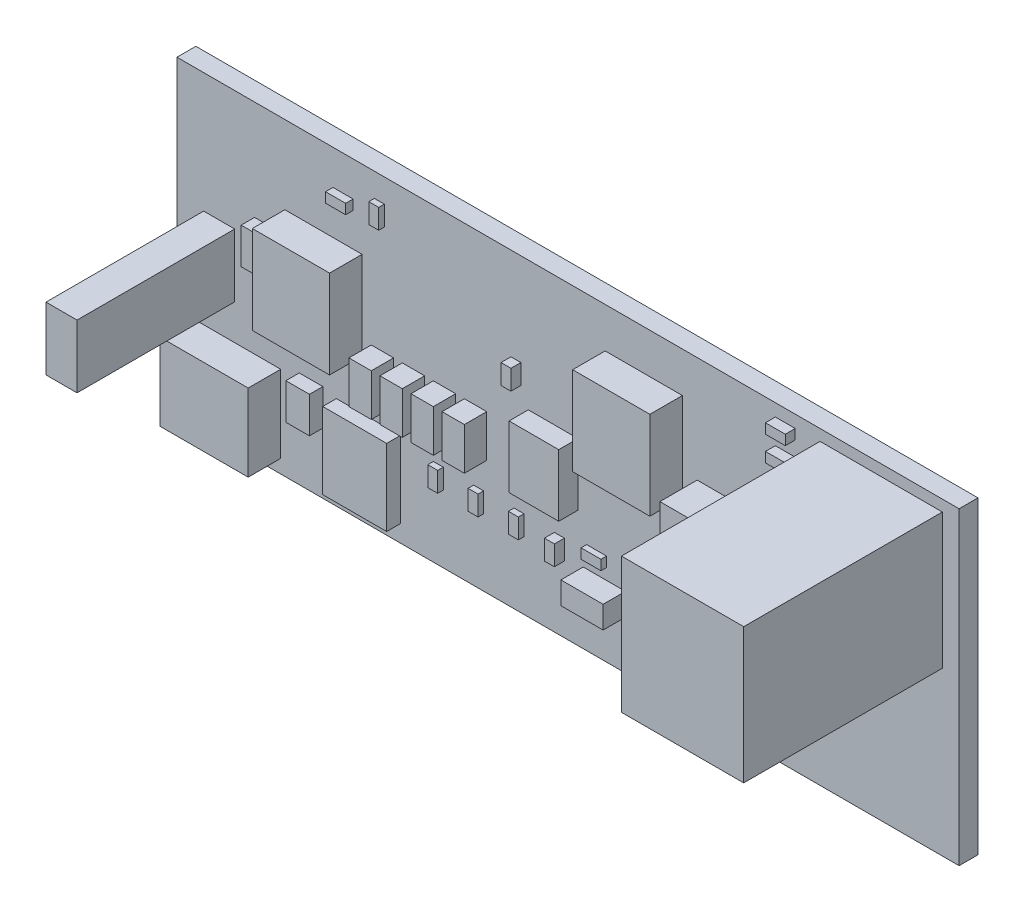
from build123d import *

# Parameters (mm, degrees)
SKETCH_1_W                  = 63
SKETCH_1_H                  = 24.9
BOARD_DEPTH                 = 1.522
SKETCH_2_W                  = 2.5
SKETCH_2_H                  = 5.08
TE_826629_2_1_DEPTH         = 12.7
EXTRUDE_C1206_1_DEPTH       = 1.8
SKETCH_4_W                  = 1.9
SKETCH_4_H                  = 2.9
DO_219AB_1_DEPTH            = 1.08
EXTRUDE_C1206_2_DEPTH       = 1.8
SKETCH_6_W                  = 0.8
SKETCH_6_H                  = 1.6001
EXTRUDE_C0603_1_DEPTH       = 0.8
SKETCH_7_W                  = 9.85
SKETCH_7_H                  = 10.9
EXTRUDE_4_1775099_0_1_DEPTH = 16
SKETCH_8_W                  = 5.15
SKETCH_8_H                  = 6.15
SON_8_1_DEPTH               = 1.1
SKETCH_9_W                  = 6.22
SKETCH_9_H                  = 7.11
DO_214AB_1_DEPTH            = 2.62
SKETCH_10_W                 = 7.11
SKETCH_10_H                 = 6.22
DO_214AB_2_DEPTH            = 2.62
SKETCH_11_W                 = 1.9
SKETCH_11_H                 = 2.9
DO_219AB_2_DEPTH            = 1.08
SKETCH_12_W                 = 6.22
SKETCH_12_H                 = 7.11
DO_214AB_3_DEPTH            = 2.62
SKETCH_13_W                 = 1.6
SKETCH_13_H                 = 0.8
EXTRUDE_R0603_1_DEPTH       = 0.45
SKETCH_14_W                 = 1.6
SKETCH_14_H                 = 0.8
EXTRUDE_R0603_2_DEPTH       = 0.45
SKETCH_15_W                 = 1.6
SKETCH_15_H                 = 0.8
EXTRUDE_R0603_3_DEPTH       = 0.45
SKETCH_16_W                 = 1.6
SKETCH_16_H                 = 0.8
EXTRUDE_R0603_4_DEPTH       = 0.45
SKETCH_17_W                 = 0.8
SKETCH_17_H                 = 1.6
EXTRUDE_R0603_5_DEPTH       = 0.45
SKETCH_18_W                 = 0.8
SKETCH_18_H                 = 1.6
EXTRUDE_R0603_6_DEPTH       = 0.45
SKETCH_19_W                 = 0.8
SKETCH_19_H                 = 1.6
EXTRUDE_R0603_7_DEPTH       = 0.45
SKETCH_20_W                 = 0.8
SKETCH_20_H                 = 1.6
EXTRUDE_R0603_8_DEPTH       = 0.45
SKETCH_21_W                 = 0.8
SKETCH_21_H                 = 1.6
EXTRUDE_R0603_9_DEPTH       = 0.45
SKETCH_22_W                 = 7.6
SKETCH_22_H                 = 6.9
SRP_2_670X660X280_1_DEPTH   = 3
SKETCH_23_W                 = 1.6201
SKETCH_23_H                 = 0.8
HL0603_1_DEPTH              = 0.6
SKETCH_24_W                 = 1.6201
SKETCH_24_H                 = 0.8
HL0603_2_DEPTH              = 0.6
SKETCH_25_W                 = 4
SKETCH_25_H                 = 5
HSOIC_8_1_DEPTH             = 1.55
SKETCH_26_W                 = 1.6001
SKETCH_26_H                 = 0.8
EXTRUDE_C0603_2_DEPTH       = 0.8
SKETCH_27_W                 = 1.6001
SKETCH_27_H                 = 0.8
EXTRUDE_C0603_3_DEPTH       = 0.8
SKETCH_28_W                 = 1.6001
SKETCH_28_H                 = 0.8
EXTRUDE_C0603_4_DEPTH       = 0.8
SKETCH_29_W                 = 1.6001
SKETCH_29_H                 = 0.8
EXTRUDE_C0603_5_DEPTH       = 0.8
SKETCH_30_W                 = 0.8
SKETCH_30_H                 = 1.6001
EXTRUDE_C0603_6_DEPTH       = 0.8
EXTRUDE_C1206_3_DEPTH       = 1.8
EXTRUDE_C1206_4_DEPTH       = 1.8
EXTRUDE_C1206_5_DEPTH       = 1.8


with BuildPart() as part:
    # Эскиз1 → BOARD (new body)
    with BuildSketch(Plane.XY):
        with Locations((31.5, 12.45)):
            Rectangle(SKETCH_1_W, SKETCH_1_H)
    extrude(amount=BOARD_DEPTH)


with BuildPart() as body_2:
    # Эскиз2 → TE_826629-2-1 (new body)
    with BuildSketch(Plane.XY.offset(1.522)):
        with Locations((3.4002, 12.6998)):
            Rectangle(SKETCH_2_W, SKETCH_2_H)
    extrude(amount=TE_826629_2_1_DEPTH)


with BuildPart() as body_3:
    # Эскиз3 → C1206-1 (new body)
    with BuildSketch(Plane.XY.offset(1.522)):
        Polygon((19.95, 11.85), (19.95, 10.05), (19.95, 9.25), (18.15, 9.25), (18.15, 10.05), (18.15, 11.85), (18.15, 12.65), (19.95, 12.65), align=None)
    extrude(amount=EXTRUDE_C1206_1_DEPTH)


with BuildPart() as body_4:
    # Эскиз4 → DO-219AB-1 (new body)
    with BuildSketch(Plane.XY.offset(1.522)):
        with Locations((7.2, 15.4)):
            Rectangle(SKETCH_4_W, SKETCH_4_H)
    extrude(amount=DO_219AB_1_DEPTH)


with BuildPart() as body_5:
    # Эскиз5 → C1206-2 (new body)
    with BuildSketch(Plane.XY.offset(1.522)):
        Polygon((35.325, 3.9), (33.525, 3.9), (32.725, 3.9), (32.725, 5.7), (33.525, 5.7), (35.325, 5.7), (36.125, 5.7), (36.125, 3.9), align=None)
    extrude(amount=EXTRUDE_C1206_2_DEPTH)


with BuildPart() as body_6:
    # Эскиз6 → C0603-1 (new body)
    with BuildSketch(Plane.XY.offset(1.522)):
        with Locations((30.8002, 6.14985)):
            Rectangle(SKETCH_6_W, SKETCH_6_H)
    extrude(amount=EXTRUDE_C0603_1_DEPTH)


with BuildPart() as body_7:
    # Эскиз7 → 4-1775099-0-1 (new body)
    with BuildSketch(Plane.XY.offset(1.522)):
        with Locations((56.7251, 18.5501)):
            Rectangle(SKETCH_7_W, SKETCH_7_H)
    extrude(amount=EXTRUDE_4_1775099_0_1_DEPTH)


with BuildPart() as body_8:
    # Эскиз8 → SON-8-1 (new body)
    with BuildSketch(Plane.XY.offset(1.522)):
        with Locations((15.415, 4.43)):
            Rectangle(SKETCH_8_W, SKETCH_8_H)
    extrude(amount=SON_8_1_DEPTH)


with BuildPart() as body_9:
    # Эскиз9 → DO-214AB-1 (new body)
    with BuildSketch(Plane.XY.offset(1.522)):
        with Locations((37.6, 18.1)):
            Rectangle(SKETCH_9_W, SKETCH_9_H)
    extrude(amount=DO_214AB_1_DEPTH)


with BuildPart() as body_10:
    # Эскиз10 → DO-214AB-2 (new body)
    with BuildSketch(Plane.XY.offset(1.522)):
        with Locations((4.8, 4.2)):
            Rectangle(SKETCH_10_W, SKETCH_10_H)
    extrude(amount=DO_214AB_2_DEPTH)


with BuildPart() as body_11:
    # Эскиз11 → DO-219AB-2 (new body)
    with BuildSketch(Plane.XY.offset(1.522)):
        with Locations((10.8, 6.35)):
            Rectangle(SKETCH_11_W, SKETCH_11_H)
    extrude(amount=DO_219AB_2_DEPTH)


with BuildPart() as body_12:
    # Эскиз12 → DO-214AB-3 (new body)
    with BuildSketch(Plane.XY.offset(1.522)):
        with Locations((11.8, 15.05)):
            Rectangle(SKETCH_12_W, SKETCH_12_H)
    extrude(amount=DO_214AB_3_DEPTH)


with BuildPart() as body_13:
    # Эскиз13 → R0603-1 (new body)
    with BuildSketch(Plane.XY.offset(1.522)):
        with Locations((50.2999, 5.0001)):
            Rectangle(SKETCH_13_W, SKETCH_13_H)
    extrude(amount=EXTRUDE_R0603_1_DEPTH)


with BuildPart() as body_14:
    # Эскиз14 → R0603-2 (new body)
    with BuildSketch(Plane.XY.offset(1.522)):
        with Locations((42.9499, 5.4501)):
            Rectangle(SKETCH_14_W, SKETCH_14_H)
    extrude(amount=EXTRUDE_R0603_2_DEPTH)


with BuildPart() as body_15:
    # Эскиз15 → R0603-3 (new body)
    with BuildSketch(Plane.XY.offset(1.522)):
        with Locations((42.9751, 3.4499)):
            Rectangle(SKETCH_15_W, SKETCH_15_H)
    extrude(amount=EXTRUDE_R0603_3_DEPTH)


with BuildPart() as body_16:
    # Эскиз16 → R0603-4 (new body)
    with BuildSketch(Plane.XY.offset(1.522)):
        with Locations((33.7999, 7.0001)):
            Rectangle(SKETCH_16_W, SKETCH_16_H)
    extrude(amount=EXTRUDE_R0603_4_DEPTH)


with BuildPart() as body_17:
    # Эскиз17 → R0603-5 (new body)
    with BuildSketch(Plane.XY.offset(1.522)):
        with Locations((27.5501, 6.2251)):
            Rectangle(SKETCH_17_W, SKETCH_17_H)
    extrude(amount=EXTRUDE_R0603_5_DEPTH)


with BuildPart() as body_18:
    # Эскиз18 → R0603-6 (new body)
    with BuildSketch(Plane.XY.offset(1.522)):
        with Locations((21.0499, 6.2249)):
            Rectangle(SKETCH_18_W, SKETCH_18_H)
    extrude(amount=EXTRUDE_R0603_6_DEPTH)


with BuildPart() as body_19:
    # Эскиз19 → R0603-7 (new body)
    with BuildSketch(Plane.XY.offset(1.522)):
        with Locations((24.3001, 6.2001)):
            Rectangle(SKETCH_19_W, SKETCH_19_H)
    extrude(amount=EXTRUDE_R0603_7_DEPTH)


with BuildPart() as body_20:
    # Эскиз20 → R0603-8 (new body)
    with BuildSketch(Plane.XY.offset(1.522)):
        with Locations((7.3001, 11.2001)):
            Rectangle(SKETCH_20_W, SKETCH_20_H)
    extrude(amount=EXTRUDE_R0603_8_DEPTH)


with BuildPart() as body_21:
    # Эскиз21 → R0603-9 (new body)
    with BuildSketch(Plane.XY.offset(1.522)):
        with Locations((16.2999, 22.1999)):
            Rectangle(SKETCH_21_W, SKETCH_21_H)
    extrude(amount=EXTRUDE_R0603_9_DEPTH)


with BuildPart() as body_22:
    # Эскиз22 → SRP-2-670X660X280-1 (new body)
    with BuildSketch(Plane.XY.offset(1.522)):
        with Locations((45.7, 12.9)):
            Rectangle(SKETCH_22_W, SKETCH_22_H)
    extrude(amount=SRP_2_670X660X280_1_DEPTH)


with BuildPart() as body_23:
    # Эскиз23 → HL0603-1 (new body)
    with BuildSketch(Plane.XY.offset(1.522)):
        with Locations((50.27505, 3.1749)):
            Rectangle(SKETCH_23_W, SKETCH_23_H)
    extrude(amount=HL0603_1_DEPTH)


with BuildPart() as body_24:
    # Эскиз24 → HL0603-2 (new body)
    with BuildSketch(Plane.XY.offset(1.522)):
        with Locations((13.37505, 21.6999)):
            Rectangle(SKETCH_24_W, SKETCH_24_H)
    extrude(amount=HL0603_2_DEPTH)


with BuildPart() as body_25:
    # Эскиз25 → HSOIC-8-1 (new body)
    with BuildSketch(Plane.XY.offset(1.522)):
        with Locations((30.3, 11.95)):
            Rectangle(SKETCH_25_W, SKETCH_25_H)
    extrude(amount=HSOIC_8_1_DEPTH)


with BuildPart() as body_26:
    # Эскиз26 → C0603-2 (new body)
    with BuildSketch(Plane.XY.offset(1.522)):
        with Locations((48.99985, 23.4998)):
            Rectangle(SKETCH_26_W, SKETCH_26_H)
    extrude(amount=EXTRUDE_C0603_2_DEPTH)


with BuildPart() as body_27:
    # Эскиз27 → C0603-3 (new body)
    with BuildSketch(Plane.XY.offset(1.522)):
        with Locations((48.99985, 21.4998)):
            Rectangle(SKETCH_27_W, SKETCH_27_H)
    extrude(amount=EXTRUDE_C0603_3_DEPTH)


with BuildPart() as body_28:
    # Эскиз28 → C0603-4 (new body)
    with BuildSketch(Plane.XY.offset(1.522)):
        with Locations((48.94985, 19.4998)):
            Rectangle(SKETCH_28_W, SKETCH_28_H)
    extrude(amount=EXTRUDE_C0603_4_DEPTH)


with BuildPart() as body_29:
    # Эскиз29 → C0603-5 (new body)
    with BuildSketch(Plane.XY.offset(1.522)):
        with Locations((48.99985, 17.4998)):
            Rectangle(SKETCH_29_W, SKETCH_29_H)
    extrude(amount=EXTRUDE_C0603_5_DEPTH)


with BuildPart() as body_30:
    # Эскиз30 → C0603-6 (new body)
    with BuildSketch(Plane.XY.offset(1.522)):
        with Locations((27.2998, 16.65015)):
            Rectangle(SKETCH_30_W, SKETCH_30_H)
    extrude(amount=EXTRUDE_C0603_6_DEPTH)


with BuildPart() as body_31:
    # Эскиз31 → C1206-3 (new body)
    with BuildSketch(Plane.XY.offset(1.522)):
        Polygon((24.95, 11.85), (24.95, 10.05), (24.95, 9.25), (23.15, 9.25), (23.15, 10.05), (23.15, 11.85), (23.15, 12.65), (24.95, 12.65), align=None)
    extrude(amount=EXTRUDE_C1206_3_DEPTH)


with BuildPart() as body_32:
    # Эскиз32 → C1206-4 (new body)
    with BuildSketch(Plane.XY.offset(1.522)):
        Polygon((22.45, 11.85), (22.45, 10.05), (22.45, 9.25), (20.65, 9.25), (20.65, 10.05), (20.65, 11.85), (20.65, 12.65), (22.45, 12.65), align=None)
    extrude(amount=EXTRUDE_C1206_4_DEPTH)


with BuildPart() as body_33:
    # Эскиз33 → C1206-5 (new body)
    with BuildSketch(Plane.XY.offset(1.522)):
        Polygon((17.45, 11.85), (17.45, 10.05), (17.45, 9.25), (15.65, 9.25), (15.65, 10.05), (15.65, 11.85), (15.65, 12.65), (17.45, 12.65), align=None)
    extrude(amount=EXTRUDE_C1206_5_DEPTH)


solid = Compound([part.part, body_2.part, body_3.part, body_4.part, body_5.part, body_6.part, body_7.part, body_8.part, body_9.part, body_10.part, body_11.part, body_12.part, body_13.part, body_14.part, body_15.part, body_16.part, body_17.part, body_18.part, body_19.part, body_20.part, body_21.part, body_22.part, body_23.part, body_24.part, body_25.part, body_26.part, body_27.part, body_28.part, body_29.part, body_30.part, body_31.part, body_32.part, body_33.part])
